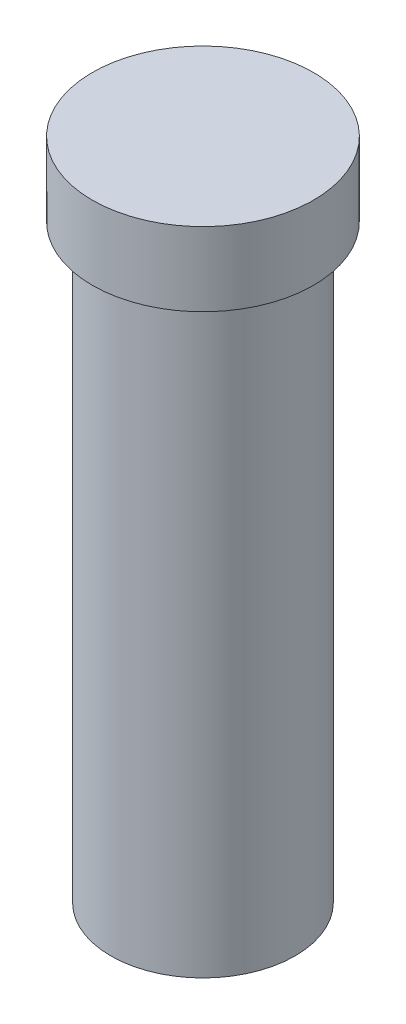
from build123d import *

# Parameters (mm, degrees)
CROQUIS1_R              = 12.5
SALIENTE_EXTRUIR1_DEPTH = 45
CROQUIS2_R              = 15
SALIENTE_EXTRUIR2_DEPTH = 10


with BuildPart() as part:
    # Croquis1 → Saliente-Extruir1 (new body, symmetric)
    with BuildSketch(Plane(origin=(0, 0, 0), x_dir=(1, 0, 0), z_dir=(0, 1, 0))):
        Circle(CROQUIS1_R)
    extrude(amount=SALIENTE_EXTRUIR1_DEPTH, both=True)

    # Croquis2 → Saliente-Extruir2 (add)
    with BuildSketch(Plane(origin=(0, 45, 0), x_dir=(1, 0, 0), z_dir=(0, 1, 0))):
        Circle(CROQUIS2_R)
    extrude(amount=-SALIENTE_EXTRUIR2_DEPTH)


solid = part.part
